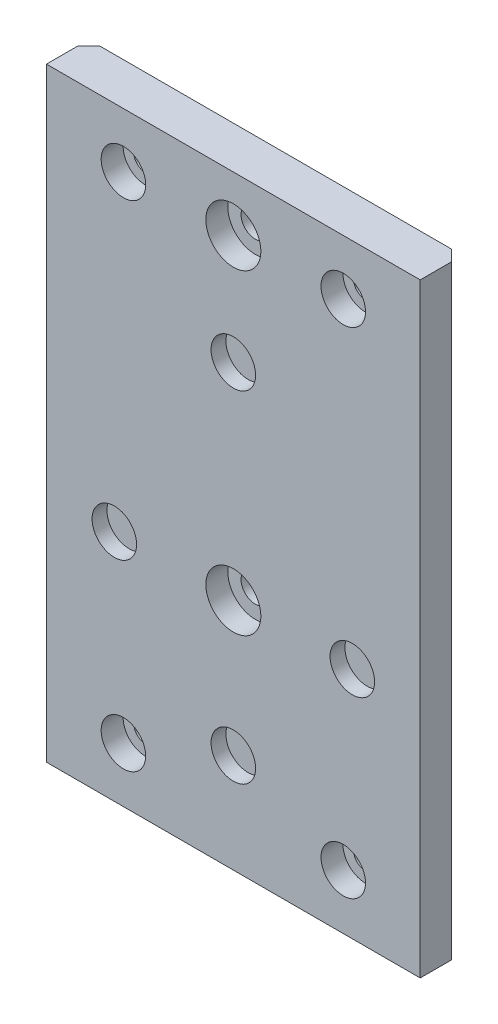
from build123d import *

# Parameters (mm, degrees)
SKETCH1_W           = 68
SKETCH1_H           = 110
SKETCH1_R           = 2.1
SKETCH1_R_2         = 4.05
SKETCH1_R_3         = 2.6
BOSS_EXTRUDE1_DEPTH = 7.7
SKETCH2_R           = 6.304633146
SKETCH2_R_2         = 7.334333348
SKETCH2_R_3         = 8.114040952
SKETCH2_R_4         = 11.073656437
BOSS_EXTRUDE2_DEPTH = 5
SKETCH3_R           = 4.05
SKETCH3_R_2         = 5
CUT_EXTRUDE1_DEPTH  = 4
CUT_EXTRUDE2_DEPTH  = 111


with BuildPart() as part:
    # Sketch1 → Boss-Extrude1 (new body)
    with BuildSketch(Plane.XY):
        Rectangle(SKETCH1_W, SKETCH1_H)
        with Locations((20, 45)):
            Circle(SKETCH1_R, mode=Mode.SUBTRACT)
        with Locations((-20, 45)):
            Circle(SKETCH1_R, mode=Mode.SUBTRACT)
        with Locations((20, -45)):
            Circle(SKETCH1_R, mode=Mode.SUBTRACT)
        with Locations((-20, -45)):
            Circle(SKETCH1_R, mode=Mode.SUBTRACT)
        with Locations((21.650635095, -12.5)):
            Circle(SKETCH1_R_2, mode=Mode.SUBTRACT)
        with Locations((0, 25)):
            Circle(SKETCH1_R_2, mode=Mode.SUBTRACT)
        with Locations((-21.650635095, -12.5)):
            Circle(SKETCH1_R_2, mode=Mode.SUBTRACT)
        with Locations((0, -36.95)):
            Circle(SKETCH1_R_2, mode=Mode.SUBTRACT)
        with Locations((0, 45)):
            Circle(SKETCH1_R_3, mode=Mode.SUBTRACT)
        with Locations((0, -12.5)):
            Circle(SKETCH1_R_3, mode=Mode.SUBTRACT)
    extrude(amount=BOSS_EXTRUDE1_DEPTH)

    # Sketch2 → Boss-Extrude2 (add)
    with BuildSketch(Plane(origin=(0, 0, 0), x_dir=(-1, 0, 0), z_dir=(0, 0, -1))):
        with Locations((-21.650635095, -12.5)):
            Circle(SKETCH2_R)
        with Locations((0, 25)):
            Circle(SKETCH2_R_2)
        with Locations((21.650635095, -12.5)):
            Circle(SKETCH2_R_3)
        with Locations((0, -36.95)):
            Circle(SKETCH2_R_4)
    extrude(amount=-BOSS_EXTRUDE2_DEPTH)

    # Sketch3 → Cut-Extrude1 (cut)
    with BuildSketch(Plane(origin=(0, 0, 7.7), x_dir=(-1, 0, 0), z_dir=(0, 0, -1))):
        with Locations((-20, 45)):
            Circle(SKETCH3_R)
        with Locations((20, 45)):
            Circle(SKETCH3_R)
        with Locations((-20, -45)):
            Circle(SKETCH3_R)
        with Locations((20, -45)):
            Circle(SKETCH3_R)
        with Locations((0, 45)):
            Circle(SKETCH3_R_2)
        with Locations((0, -12.5)):
            Circle(SKETCH3_R_2)
    extrude(amount=CUT_EXTRUDE1_DEPTH, mode=Mode.SUBTRACT)

    # Sketch4 → Cut-Extrude2 (cut, through all)
    with BuildSketch(Plane.XZ.offset(55)):
        Polygon((34, 2), (34, 0), (32, 0), align=None)
        Polygon((-34, 15.4), (-39, 15.4), (-39, 0), (-34, 0), (-32, 0), (-34, 2), align=None)
    extrude(amount=-CUT_EXTRUDE2_DEPTH, mode=Mode.SUBTRACT)


solid = part.part
